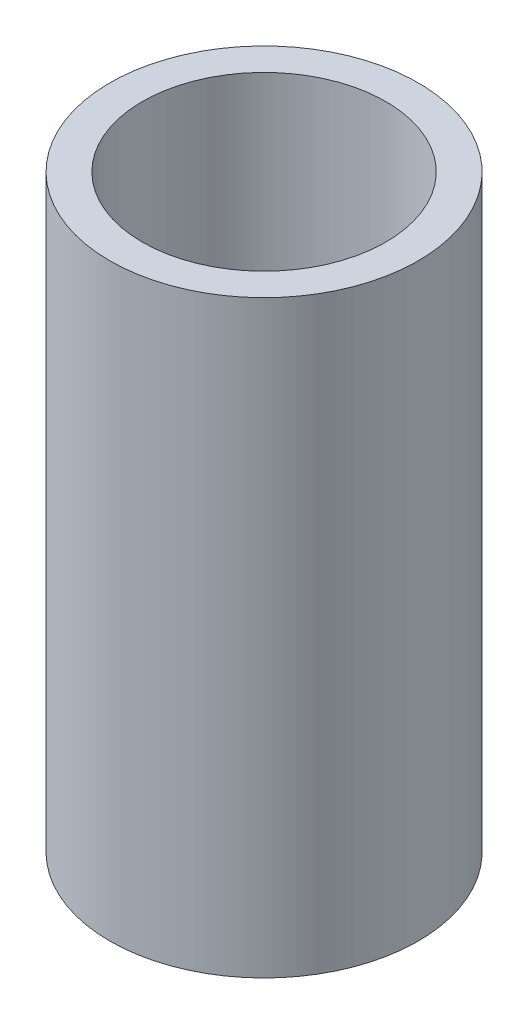
from build123d import *

# Parameters (mm, degrees)
SKETCH_1_R      = 3.925
SKETCH_1_R_2    = 3.1
EXTRUDE_1_DEPTH = 15


with BuildPart() as part:
    # ｽｹｯﾁ1 → ﾎﾞｽ - 押し出し1 (new body)
    with BuildSketch(Plane(origin=(0, 0, 0), x_dir=(1, 0, 0), z_dir=(0, 1, 0))):
        Circle(SKETCH_1_R)
        Circle(SKETCH_1_R_2, mode=Mode.SUBTRACT)
    extrude(amount=EXTRUDE_1_DEPTH)


solid = part.part
